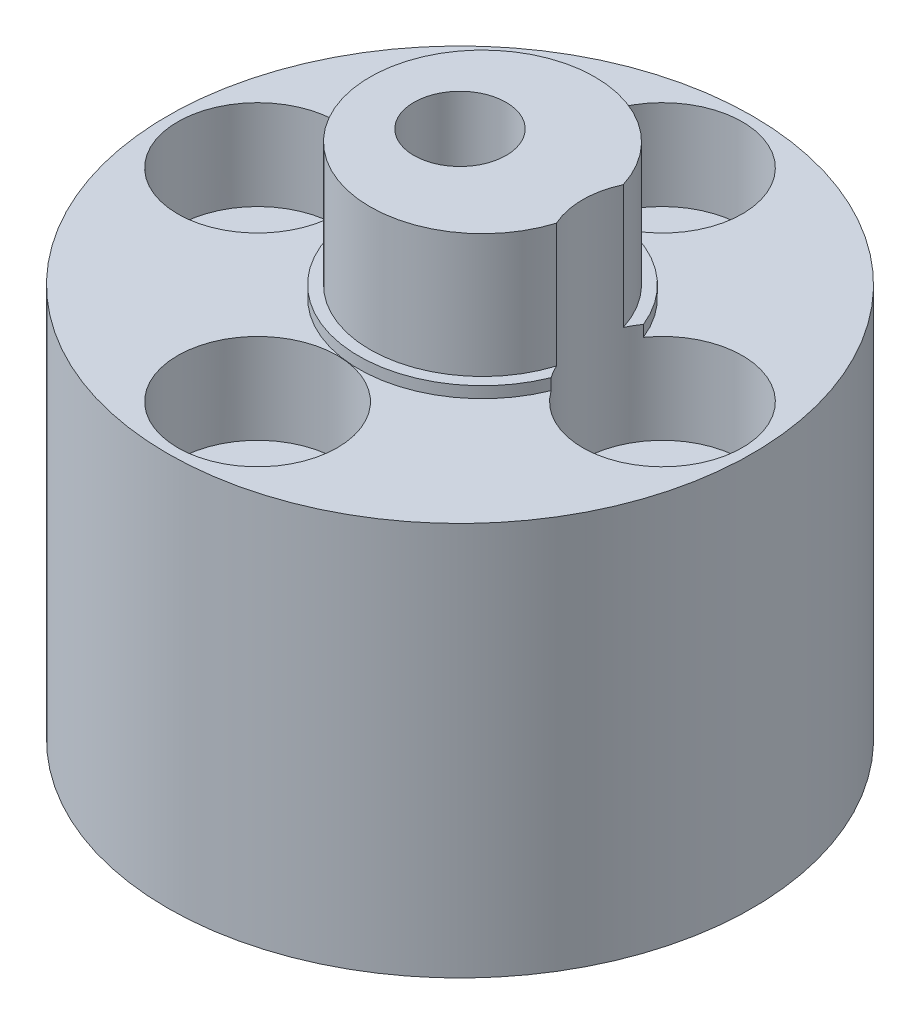
from build123d import *

# Parameters (mm, degrees)
SKETCH1_R           = 13
BOSS_EXTRUDE1_DEPTH = 17.5
SKETCH6_R           = 5
BOSS_EXTRUDE2_DEPTH = 6
SKETCH7_R           = 5.5
BOSS_EXTRUDE3_DEPTH = 0.5
SKETCH2_R           = 1.65
CUT_EXTRUDE1_DEPTH  = 24.5
CUT_EXTRUDE3_START  = -4
SKETCH5_R           = 3.55
CUT_EXTRUDE3_DEPTH  = 11
CIRPATTERN1_COUNT   = 4
SKETCH3_R           = 2.05
CUT_EXTRUDE2_DEPTH  = 24.5
SKETCH8_R           = 2.75
CUT_EXTRUDE4_DEPTH  = 10
CUT_EXTRUDE5_DEPTH  = 10


with BuildPart() as part:
    # Sketch1 → Boss-Extrude1 (new body)
    with BuildSketch(Plane(origin=(0, 0, 0), x_dir=(1, 0, 0), z_dir=(0, 1, 0))):
        Circle(SKETCH1_R)
    extrude(amount=BOSS_EXTRUDE1_DEPTH)

    # Sketch6 → Boss-Extrude2 (add)
    with BuildSketch(Plane(origin=(0, 17.5, 0), x_dir=(1, 0, 0), z_dir=(0, 1, 0))):
        with Locations((1, 0)):
            Circle(SKETCH6_R)
    extrude(amount=BOSS_EXTRUDE2_DEPTH)

    # Sketch7 → Boss-Extrude3 (add)
    with BuildSketch(Plane(origin=(0, 17.5, 0), x_dir=(1, 0, 0), z_dir=(0, 1, 0))):
        with Locations((1, 0)):
            Circle(SKETCH7_R)
    extrude(amount=BOSS_EXTRUDE3_DEPTH)

    # Sketch2 → Cut-Extrude1 (cut, through all)
    with BuildSketch(Plane(origin=(0, 0, 0), x_dir=(1, 0, 0), z_dir=(0, 1, 0))):
        with Locations((0, 9)):
            Circle(SKETCH2_R)
    cut_extrude1 = extrude(amount=CUT_EXTRUDE1_DEPTH, mode=Mode.SUBTRACT)

    # Sketch5 → Cut-Extrude3 (cut)
    with BuildSketch(Plane(origin=(0, 17.5, 0), x_dir=(1, 0, 0), z_dir=(0, 1, 0)).offset(CUT_EXTRUDE3_START)):
        with Locations((0, 9)):
            Circle(SKETCH5_R)
    cut_extrude3 = extrude(amount=CUT_EXTRUDE3_DEPTH, mode=Mode.SUBTRACT)

    # CirPattern1: Cut-Extrude1, Cut-Extrude3 ×4 about axis
    cirpattern1_axis = Axis((0, 0, 0), (0, 1, 0))
    for i in range(1, CIRPATTERN1_COUNT):
        add(cut_extrude1.rotate(cirpattern1_axis, i * 360 / CIRPATTERN1_COUNT), mode=Mode.SUBTRACT)
        add(cut_extrude3.rotate(cirpattern1_axis, i * 360 / CIRPATTERN1_COUNT), mode=Mode.SUBTRACT)

    # Sketch3 → Cut-Extrude2 (cut, through all)
    with BuildSketch(Plane(origin=(0, 0, 0), x_dir=(1, 0, 0), z_dir=(0, 1, 0))):
        Circle(SKETCH3_R)
    extrude(amount=CUT_EXTRUDE2_DEPTH, mode=Mode.SUBTRACT)

    # Sketch8 → Cut-Extrude4 (cut)
    with BuildSketch(Plane.XZ):
        Circle(SKETCH8_R)
    extrude(amount=-CUT_EXTRUDE4_DEPTH, mode=Mode.SUBTRACT)

    # Sketch10 → Cut-Extrude5 (cut)
    with BuildSketch(Plane.XZ):
        Polygon((4.618802154, 0), (2.309401077, 4), (-2.309401077, 4), (-4.618802154, 0), (-2.309401077, -4), (2.309401077, -4), align=None)
    extrude(amount=-CUT_EXTRUDE5_DEPTH, mode=Mode.SUBTRACT)


solid = part.part
